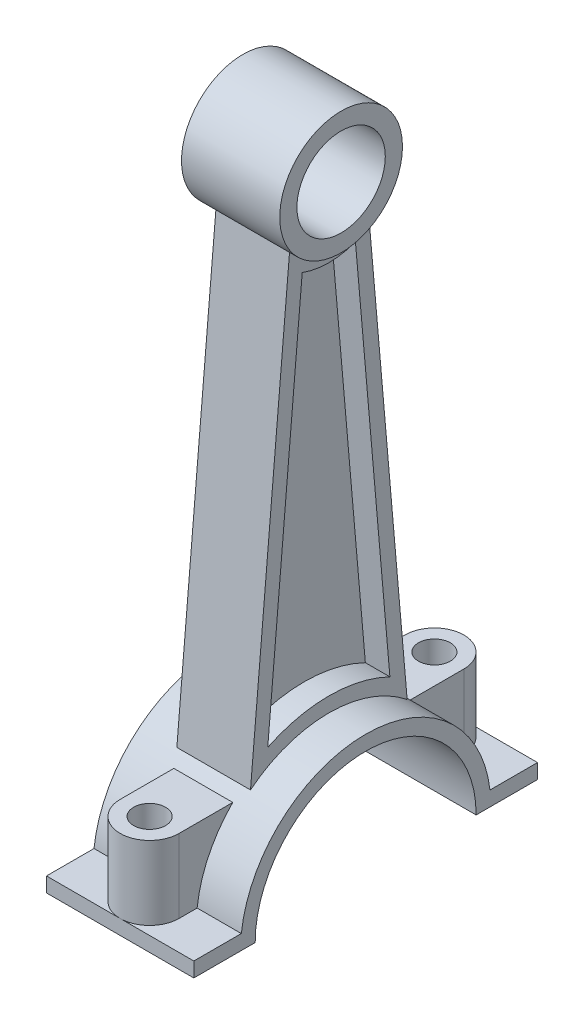
from build123d import *

# Parameters (mm, degrees)
SKETCH1_R           = 9
BOSS_EXTRUDE1_DEPTH = 10
BOSS_EXTRUDE2_DEPTH = 15
BOSS_EXTRUDE3_DEPTH = 7.5
BOSS_EXTRUDE4_DEPTH = 15
SKETCH3_R           = 3.25
CUT_EXTRUDE1_DEPTH  = 122.045487318
SKETCH4_R           = 22.5
CUT_EXTRUDE2_DEPTH  = 151
CUT_EXTRUDE3_DEPTH  = 5


with BuildPart() as part:
    # Sketch1 → Boss-Extrude1 (new, symmetric)
    with BuildSketch(Plane(origin=(0, 0, 0), x_dir=(0, 0, -1), z_dir=(1, 0, 0))):
        with BuildLine():
            ThreePointArc((-8, -9.604686356), (0, -12.5), (8, -9.604686356))
            ThreePointArc((8, -9.604686356), (11.319231423, -5.303300859), (12.5, 0))
            ThreePointArc((12.5, 0), (-5.303300859, 11.319231423), (-8, -9.604686356))
        make_face()
        Circle(SKETCH1_R, mode=Mode.SUBTRACT)
    extrude(amount=BOSS_EXTRUDE1_DEPTH, both=True)



with BuildPart() as body_2:
    # Sketch1_3 → Boss-Extrude2 (new, symmetric)
    with BuildSketch(Plane(origin=(0, 0, 0), x_dir=(0, 0, -1), z_dir=(1, 0, 0))):
        with BuildLine():
            Line((22.5, -120.4), (35, -120.4))
            Line((35, -120.4), (35, -117.4))
            Line((35, -117.4), (25.322914524, -117.4))
            ThreePointArc((25.322914524, -117.4), (0, -94.9), (-25.322914524, -117.4))
            Line((-25.322914524, -117.4), (-35, -117.4))
            Line((-35, -117.4), (-35, -120.4))
            Line((-35, -120.4), (-22.5, -120.4))
            ThreePointArc((-22.5, -120.4), (0, -97.9), (22.5, -120.4))
        make_face()
    extrude(amount=BOSS_EXTRUDE2_DEPTH, both=True)


with BuildPart() as part_1:
    add(part.part)

    add(body_2.part)  # Boss-Extrude3 merges body 2
    # Sketch1_7 → Boss-Extrude3 (add, symmetric)
    with BuildSketch(Plane(origin=(0, 0, 0), x_dir=(0, 0, -1), z_dir=(1, 0, 0))):
        with BuildLine():
            ThreePointArc((-15.952867936, -100.506382817), (0, -94.9), (15.952867936, -100.506382817))
            Line((15.952867936, -100.506382817), (8, -9.604686356))
            ThreePointArc((8, -9.604686356), (0, -12.5), (-8, -9.604686356))
            Line((-8, -9.604686356), (-15.952867936, -100.506382817))
        make_face()
    extrude(amount=BOSS_EXTRUDE3_DEPTH, both=True)

    # Sketch2 → Boss-Extrude4 (add)
    with BuildSketch(Plane(origin=(0, -117.4, 0), x_dir=(1, 0, 0), z_dir=(0, 1, 0))):
        with BuildLine():
            Line((-6, 29), (-6, 17))
            Line((-6, 17), (6, 17))
            Line((6, 17), (6, 29))
            ThreePointArc((6, 29), (0, 35), (-6, 29))
        make_face()
    boss_extrude4 = extrude(amount=BOSS_EXTRUDE4_DEPTH)

    # Sketch3 → Cut-Extrude1 (cut, through all)
    with BuildSketch(Plane(origin=(0, -102.4, 0), x_dir=(1, 0, 0), z_dir=(0, 1, 0))):
        with Locations((0, 29)):
            Circle(SKETCH3_R)
    cut_extrude1 = extrude(amount=-CUT_EXTRUDE1_DEPTH, mode=Mode.SUBTRACT)

    # Mirror1: Boss-Extrude4, Cut-Extrude1 across plane
    add(boss_extrude4.mirror(Plane.XY))
    add(cut_extrude1.mirror(Plane.XY), mode=Mode.SUBTRACT)

    # Sketch4 → Cut-Extrude2 (cut)
    with BuildSketch(Plane(origin=(15, 0, 0), x_dir=(0, 0, -1), z_dir=(1, 0, 0))):
        with Locations((0, -120.4)):
            Circle(SKETCH4_R)
    extrude(amount=-CUT_EXTRUDE2_DEPTH, mode=Mode.SUBTRACT)

    # Sketch5 → Cut-Extrude3 (cut)
    with BuildSketch(Plane(origin=(7.5, 0, 0), x_dir=(0, 0, -1), z_dir=(1, 0, 0))):
        with BuildLine():
            Line((12.438451255, -94.757556076), (5.4187458, -14.521955583))
            ThreePointArc((5.4187458, -14.521955583), (0, -15.5), (-5.4187458, -14.521955583))
            Line((-5.4187458, -14.521955583), (-12.438451255, -94.757556076))
            ThreePointArc((-12.438451255, -94.757556076), (0, -91.9), (12.438451255, -94.757556076))
        make_face()
    cut_extrude3 = extrude(amount=-CUT_EXTRUDE3_DEPTH, mode=Mode.SUBTRACT)

    # Mirror2: Cut-Extrude3 across plane
    add(cut_extrude3.mirror(Plane(origin=(0, 0, 0), x_dir=(0, 0, 1), z_dir=(1, 0, 0))), mode=Mode.SUBTRACT)


solid = part_1.part
